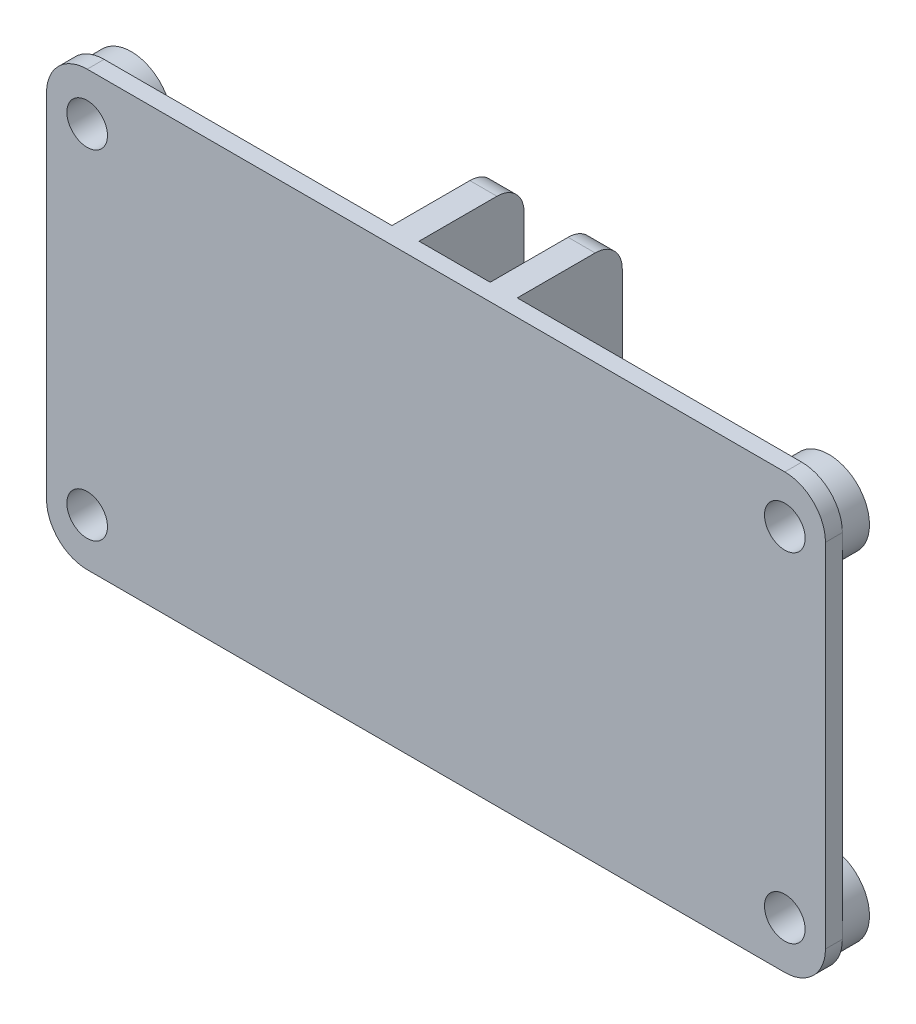
from build123d import *

# Parameters (mm, degrees)
ESQUISSE1_W                  = 57.5
ESQUISSE1_H                  = 32
BOSS_EXTRU_1_DEPTH           = 9
ESQUISSE2_W                  = 24.25
ESQUISSE2_H                  = 32
ESQUISSE2_W_2                = 24
ESQUISSE2_W_3                = 5.25
ENL_V_MAT_EXTRU_1_DEPTH      = 7.75
ESQUISSE3_R                  = 1.55
ENL_V_MAT_EXTRU_2_DEPTH      = 34.5
CONG_1_R                     = 3
CONG_2_R                     = 2
ESQUISSE10_R                 = 3
BOSS_EXTRU_2_DEPTH           = 2
ESQUISSE9_R                  = 1.5
ENL_V_MAT_EXTRU_3_DEPTH      = 8.75
ENL_V_MAT_EXTRU_3_DEPTH_BACK = 2.25


with BuildPart() as part:
    # Esquisse1 → Boss.-Extru.1 (new body)
    with BuildSketch(Plane.XY):
        with Locations((28.75, 16)):
            Rectangle(ESQUISSE1_W, ESQUISSE1_H)
    extrude(amount=BOSS_EXTRU_1_DEPTH)

    # Esquisse2 → Enlèv. mat.-Extru.1 (cut)
    with BuildSketch(Plane(origin=(0, 0, 0), x_dir=(-1, 0, 0), z_dir=(0, 0, -1))):
        with Locations((-12.125, 16)):
            Rectangle(ESQUISSE2_W, ESQUISSE2_H)
        with Locations((-45.5, 16)):
            Rectangle(ESQUISSE2_W_2, ESQUISSE2_H)
        with Locations((-28.875, 16)):
            Rectangle(ESQUISSE2_W_3, ESQUISSE2_H)
    extrude(amount=-ENL_V_MAT_EXTRU_1_DEPTH, mode=Mode.SUBTRACT)

    # Esquisse3 → Enlèv. mat.-Extru.2 (cut, through all)
    with BuildSketch(Plane(origin=(33.5, 0, 0), x_dir=(0, 0, -1), z_dir=(1, 0, 0))):
        with Locations((-3.5, 10)):
            Circle(ESQUISSE3_R)
        with Locations((-3.5, 20)):
            Circle(ESQUISSE3_R)
    extrude(amount=-ENL_V_MAT_EXTRU_2_DEPTH, mode=Mode.SUBTRACT)

    # Congé1
    cong_1_edges = [part.edges().sort_by_distance(p)[0] for p in [
        (0, 32, 8.375),
        (57.5, 32, 8.375),
        (57.5, 0, 8.375),
        (0, 0, 8.375),
    ]]
    fillet(cong_1_edges, radius=CONG_1_R)

    # Congé2
    cong_2_edges = [part.edges().sort_by_distance(p)[0] for p in [
        (32.5, 32, 0),
        (25.25, 32, 0),
        (25.25, 0, 0),
        (32.5, 0, 0),
    ]]
    fillet(cong_2_edges, radius=CONG_2_R)

    # Esquisse10 → Boss.-Extru.2 (add)
    with BuildSketch(Plane(origin=(0, 0, 7.75), x_dir=(-1, 0, 0), z_dir=(0, 0, -1))):
        with Locations((-54.5, 28.5)):
            Circle(ESQUISSE10_R)
        with Locations((-54.5, 3.5)):
            Circle(ESQUISSE10_R)
        with Locations((-3, 3.5)):
            Circle(ESQUISSE10_R)
        with Locations((-3, 28.5)):
            Circle(ESQUISSE10_R)
    extrude(amount=BOSS_EXTRU_2_DEPTH)

    # Esquisse9 → Enlèv. mat.-Extru.3 (cut, two sides)
    with BuildSketch(Plane(origin=(0, 0, 7.75), x_dir=(-1, 0, 0), z_dir=(0, 0, -1))) as enl_v_mat_extru_3_sk:
        with Locations((-54.5, 28.5)):
            Circle(ESQUISSE9_R)
        with Locations((-3, 28.5)):
            Circle(ESQUISSE9_R)
        with Locations((-3, 3.5)):
            Circle(ESQUISSE9_R)
        with Locations((-54.5, 3.5)):
            Circle(ESQUISSE9_R)
    extrude(amount=ENL_V_MAT_EXTRU_3_DEPTH, mode=Mode.SUBTRACT)
    extrude(enl_v_mat_extru_3_sk.sketch, amount=-ENL_V_MAT_EXTRU_3_DEPTH_BACK, mode=Mode.SUBTRACT)


solid = part.part
